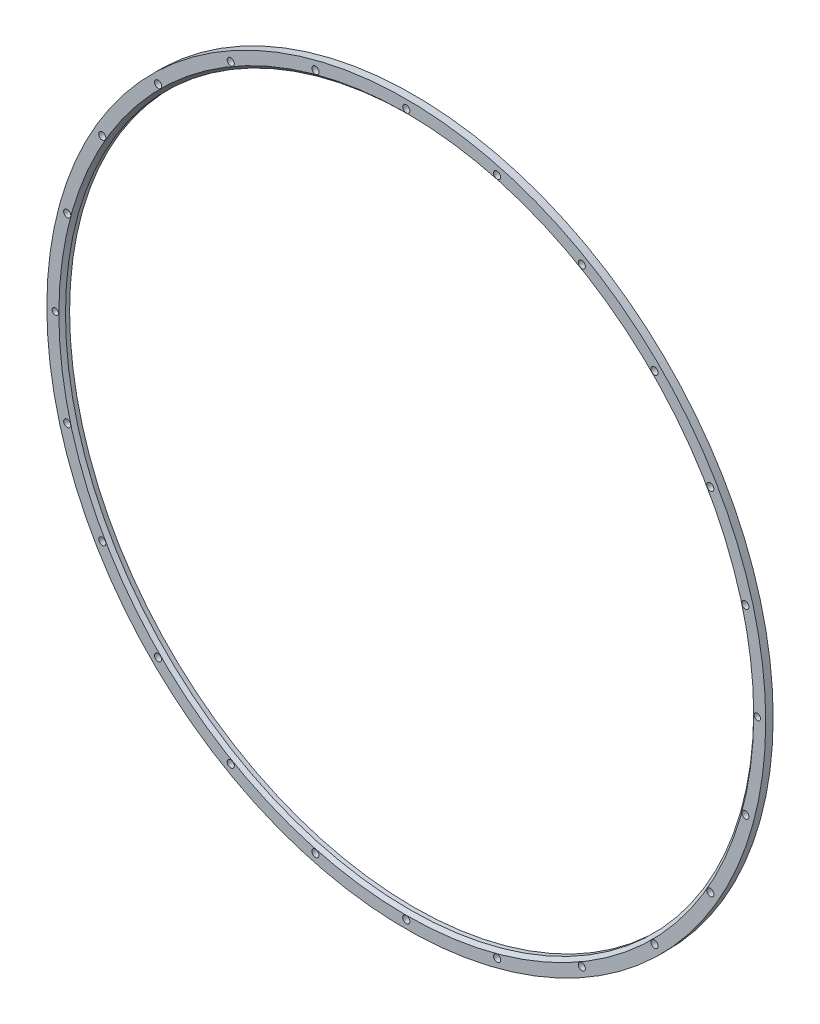
from build123d import *

# Parameters (mm, degrees)
SKETCH1_R            = 227.325
SKETCH1_R_2          = 203.325
EXTRUDE1_DEPTH       = 4.7
SKETCH2_R            = 217.625
EXTRUDE2_DEPTH       = 322.520452304
M4_CLEARANCE_HOLE1_D = 4.5
CIRPATTERN1_COUNT    = 24
SKETCH11_R           = 2.25
SKETCH11_R_2         = 2
BOSS_EXTRUDE2_DEPTH  = 4.7
CHAMFER1_SIZE        = 2.1


with BuildPart() as part:
    # Sketch1 → Extrude1 (new body)
    with BuildSketch(Plane.XY):
        Circle(SKETCH1_R)
        Circle(SKETCH1_R_2, mode=Mode.SUBTRACT)
    extrude(amount=EXTRUDE1_DEPTH)

    # Sketch2 → Extrude2 (cut, through all)
    with BuildSketch(Plane(origin=(0, 0, 0), x_dir=(-1, 0, 0), z_dir=(0, 0, -1))):
        Circle(SKETCH2_R)
    extrude(amount=-EXTRUDE2_DEPTH, mode=Mode.SUBTRACT)

    # M4 Clearance Hole1 (through all)
    with Locations(Plane.XY.offset(4.7)):
        with Locations((0, 222)):
            m4_clearance_hole1 = Hole(M4_CLEARANCE_HOLE1_D / 2)

    # CirPattern1: M4 Clearance Hole1 ×24 about axis
    cirpattern1_axis = Axis((0, 0, 0), (0, 0, 1))
    for i in range(1, CIRPATTERN1_COUNT):
        add(m4_clearance_hole1.rotate(cirpattern1_axis, i * 360 / CIRPATTERN1_COUNT), mode=Mode.SUBTRACT)

    # Sketch11 → Boss-Extrude2 (add)
    with BuildSketch(Plane.XY.offset(4.7)):
        with Locations((222, 0)):
            Circle(SKETCH11_R)
        with Locations((222, 0)):
            Circle(SKETCH11_R_2, mode=Mode.SUBTRACT)
        with Locations((-222, 0)):
            Circle(SKETCH11_R)
        with Locations((-222, 0)):
            Circle(SKETCH11_R_2, mode=Mode.SUBTRACT)
    extrude(amount=-BOSS_EXTRUDE2_DEPTH)

    # Chamfer1
    chamfer1_edges = [part.edges().sort_by_distance(p)[0] for p in [
        (217.625, 0, 4.7),
    ]]
    chamfer(chamfer1_edges, length=CHAMFER1_SIZE)


solid = part.part
